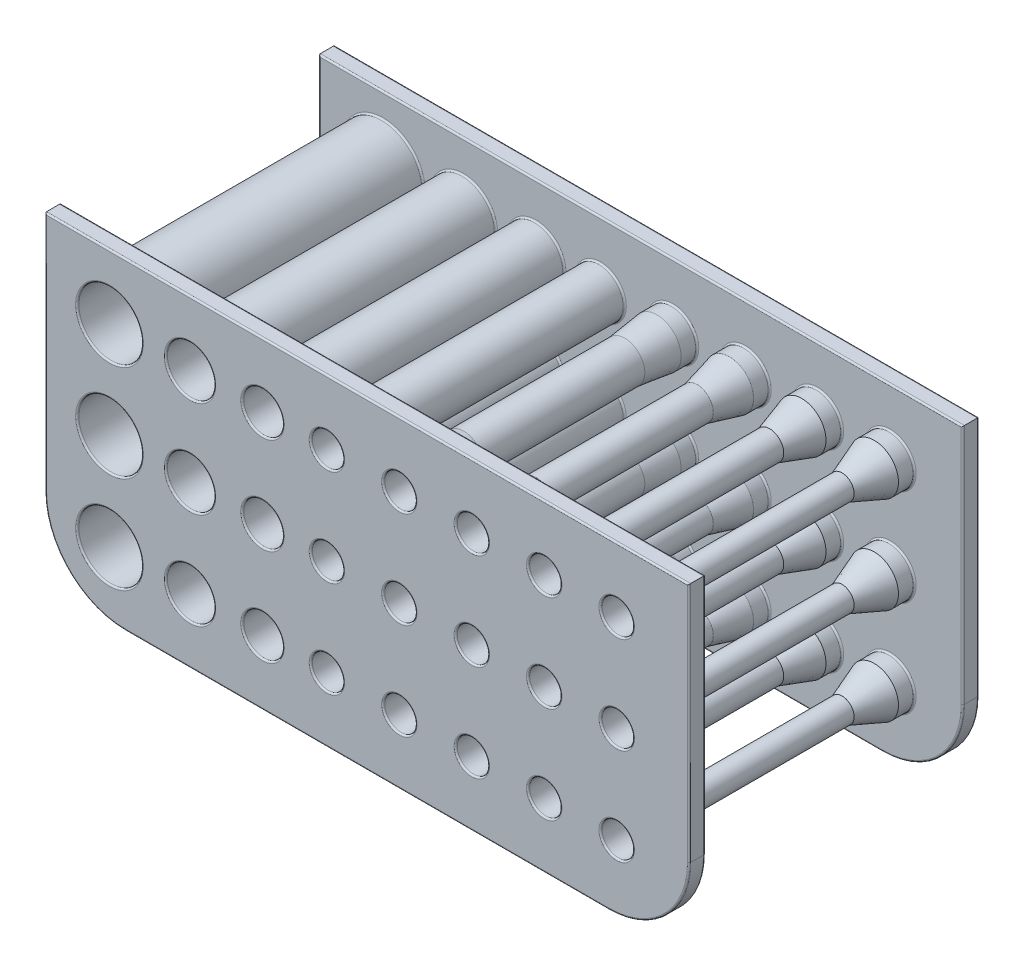
from build123d import *

# Parameters (mm, degrees)
SKIZZE1_R                   = 5
SKIZZE1_R_2                 = 4
EXTRUDE_THIN2_DEPTH         = 18
SKIZZE1_R_3                 = 3
EXTRUDE_THIN2_2_DEPTH       = 18
SKIZZE1_R_4                 = 3.5
SKIZZE1_R_5                 = 2.5
EXTRUDE_THIN2_3_DEPTH       = 18
SKIZZE1_R_6                 = 2
EXTRUDE_THIN2_4_DEPTH       = 18
SKIZZE1_R_7                 = 1.5
EXTRUDE_THIN2_5_DEPTH       = 18
SKIZZE1_R_8                 = 1
EXTRUDE_THIN2_6_DEPTH       = 18
SKIZZE1_R_9                 = 1.75
SKIZZE1_R_10                = 0.75
EXTRUDE_THIN2_7_DEPTH       = 18
SKIZZE1_R_11                = 0.5
EXTRUDE_THIN2_8_DEPTH       = 18
SKETCH1_W                   = 80
SKETCH1_H                   = 40
BOSS_EXTRUDE1_DEPTH         = 2
FILLET1_R                   = 10
LPATTERN2_COUNT             = 2
LPATTERN2_PITCH             = 34
FILLET1_OF_LPATTERN2_R      = 10
SKIZZE1_3_R                 = 4
SKIZZE1_3_R_2               = 3
SKIZZE1_3_R_3               = 2.5
SKIZZE1_3_R_4               = 2
SKIZZE1_3_R_5               = 1.5
SKIZZE1_3_R_6               = 1
SKIZZE1_3_R_7               = 0.75
SKIZZE1_3_R_8               = 0.5
CUT_EXTRUDE1_DEPTH          = 18
SKETCH7_R                   = 3
CUT_EXTRUDE2_DEPTH          = 8
SKETCH7_3_R                 = 3
SKETCH7_3_R_2               = 2
EXTRUDE_THIN3_DEPTH         = 4
LPATTERN5_COUNT             = 2
LPATTERN5_PITCH             = 12
LPATTERN5_COUNT_DIR2        = 2
LPATTERN5_PITCH_DIR2        = 12
LPATTERN5_COPY_1_SKETCH_R   = 3
LPATTERN5_COPY_1_DEPTH      = 8
LPATTERN5_COPY_2_SKETCH_R   = 3
LPATTERN5_COPY_2_DEPTH      = 8
LPATTERN5_COPY_3_SKETCH_R   = 3
LPATTERN5_COPY_3_DEPTH      = 8
LPATTERN5_COPY_4_SKETCH_R   = 3
LPATTERN5_COPY_4_SKETCH_R_2 = 2
LPATTERN5_COPY_4_DEPTH      = 4
LPATTERN5_COPY_5_SKETCH_R   = 3
LPATTERN5_COPY_5_SKETCH_R_2 = 2
LPATTERN5_COPY_5_DEPTH      = 4
LPATTERN5_COPY_6_SKETCH_R   = 3
LPATTERN5_COPY_6_SKETCH_R_2 = 2
LPATTERN5_COPY_6_DEPTH      = 4
FILLET3_R                   = 0.2


with BuildPart() as part:
    # Skizze1 → Extrude-Thin2 (new, symmetric)
    with BuildSketch(Plane.XY):
        with Locations((-32, 0)):
            Circle(SKIZZE1_R)
        with Locations((-32, 0)):
            Circle(SKIZZE1_R_2, mode=Mode.SUBTRACT)
    extrude_thin2 = extrude(amount=EXTRUDE_THIN2_DEPTH, both=True)



with BuildPart() as body_2:
    # Skizze1 → Extrude-Thin2 2 (new, symmetric)
    with BuildSketch(Plane.XY):
        with Locations((-22, 0)):
            Circle(SKIZZE1_R_2)
        with Locations((-22, 0)):
            Circle(SKIZZE1_R_3, mode=Mode.SUBTRACT)
    extrude_thin2_2 = extrude(amount=EXTRUDE_THIN2_2_DEPTH, both=True)


with BuildPart() as body_3:
    # Skizze1 → Extrude-Thin2 3 (new, symmetric)
    with BuildSketch(Plane.XY):
        with Locations((-13, 0)):
            Circle(SKIZZE1_R_4)
        with Locations((-13, 0)):
            Circle(SKIZZE1_R_5, mode=Mode.SUBTRACT)
    extrude_thin2_3 = extrude(amount=EXTRUDE_THIN2_3_DEPTH, both=True)


with BuildPart() as body_4:
    # Skizze1 → Extrude-Thin2 4 (new, symmetric)
    with BuildSketch(Plane.XY):
        with Locations((-5, 0)):
            Circle(SKIZZE1_R_3)
        with Locations((-5, 0)):
            Circle(SKIZZE1_R_6, mode=Mode.SUBTRACT)
    extrude_thin2_4 = extrude(amount=EXTRUDE_THIN2_4_DEPTH, both=True)


with BuildPart() as body_5:
    # Skizze1 → Extrude-Thin2 5 (new, symmetric)
    with BuildSketch(Plane.XY):
        with Locations((4, 0)):
            Circle(SKIZZE1_R_5)
        with Locations((4, 0)):
            Circle(SKIZZE1_R_7, mode=Mode.SUBTRACT)
    extrude_thin2_5 = extrude(amount=EXTRUDE_THIN2_5_DEPTH, both=True)


with BuildPart() as body_6:
    # Skizze1 → Extrude-Thin2 6 (new, symmetric)
    with BuildSketch(Plane.XY):
        with Locations((13, 0)):
            Circle(SKIZZE1_R_6)
        with Locations((13, 0)):
            Circle(SKIZZE1_R_8, mode=Mode.SUBTRACT)
    extrude_thin2_6 = extrude(amount=EXTRUDE_THIN2_6_DEPTH, both=True)


with BuildPart() as body_7:
    # Skizze1 → Extrude-Thin2 7 (new, symmetric)
    with BuildSketch(Plane.XY):
        with Locations((22, 0)):
            Circle(SKIZZE1_R_9)
        with Locations((22, 0)):
            Circle(SKIZZE1_R_10, mode=Mode.SUBTRACT)
    extrude_thin2_7 = extrude(amount=EXTRUDE_THIN2_7_DEPTH, both=True)


with BuildPart() as body_8:
    # Skizze1 → Extrude-Thin2 8 (new, symmetric)
    with BuildSketch(Plane.XY):
        with Locations((31, 0)):
            Circle(SKIZZE1_R_7)
        with Locations((31, 0)):
            Circle(SKIZZE1_R_11, mode=Mode.SUBTRACT)
    extrude_thin2_8 = extrude(amount=EXTRUDE_THIN2_8_DEPTH, both=True)


with BuildPart() as part_1:
    add(part.part)

    add(body_2.part)  # Boss-Extrude1 merges body 2

    add(body_3.part)  # Boss-Extrude1 merges body 3

    add(body_4.part)  # Boss-Extrude1 merges body 4

    add(body_5.part)  # Boss-Extrude1 merges body 5

    add(body_6.part)  # Boss-Extrude1 merges body 6

    add(body_7.part)  # Boss-Extrude1 merges body 7

    add(body_8.part)  # Boss-Extrude1 merges body 8
    # Sketch1 → Boss-Extrude1 (add)
    with BuildSketch(Plane.XY.offset(18)):
        Rectangle(SKETCH1_W, SKETCH1_H)
    boss_extrude1 = extrude(amount=-BOSS_EXTRUDE1_DEPTH)

    # Fillet1
    fillet1_edges = [part_1.edges().sort_by_distance(p)[0] for p in [
        (40, -20, 17),
        (-40, -20, 17),
    ]]
    fillet(fillet1_edges, radius=FILLET1_R)

    # LPattern2: Boss-Extrude1 ×2
    with Locations(*[(0, 0, -i * LPATTERN2_PITCH) for i in range(1, LPATTERN2_COUNT)]):
        add(boss_extrude1)

    # Fillet1 of LPattern2
    fillet1_of_lpattern2_edges = [part_1.edges().sort_by_distance(p)[0] for p in [
        (40, -20, -17),
        (-40, -20, -17),
    ]]
    fillet(fillet1_of_lpattern2_edges, radius=FILLET1_OF_LPATTERN2_R)

    # Skizze1_3 → Cut-Extrude1 (cut, symmetric)
    with BuildSketch(Plane.XY):
        with Locations((-32, 0)):
            Circle(SKIZZE1_3_R)
        with Locations((-22, 0)):
            Circle(SKIZZE1_3_R_2)
        with Locations((-13, 0)):
            Circle(SKIZZE1_3_R_3)
        with Locations((-5, 0)):
            Circle(SKIZZE1_3_R_4)
        with Locations((4, 0)):
            Circle(SKIZZE1_3_R_5)
        with Locations((13, 0)):
            Circle(SKIZZE1_3_R_6)
        with Locations((22, 0)):
            Circle(SKIZZE1_3_R_7)
        with Locations((31, 0)):
            Circle(SKIZZE1_3_R_8)
    cut_extrude1 = extrude(amount=CUT_EXTRUDE1_DEPTH, both=True, mode=Mode.SUBTRACT)

    # Sketch7 → Cut-Extrude2 (cut)
    with BuildSketch(Plane.XY.offset(18)):
        with Locations((31, 0)):
            Circle(SKETCH7_R)
        with Locations((22, 0)):
            Circle(SKETCH7_R)
        with Locations((13, 0)):
            Circle(SKETCH7_R)
        with Locations((4, 0)):
            Circle(SKETCH7_R)
    cut_extrude2 = extrude(amount=-CUT_EXTRUDE2_DEPTH, mode=Mode.SUBTRACT)

    # Sketch7_3 → Extrude-Thin3 (add)
    # profile 1 of 4: a face of its own
    with BuildSketch(Plane.XY.offset(18)):
        with Locations((31, 0)):
            Circle(SKETCH7_3_R)
        with Locations((31, 0)):
            Circle(SKETCH7_3_R_2, mode=Mode.SUBTRACT)
    # profile 2 of 4: a face of its own
    with BuildSketch(Plane.XY.offset(18)):
        with Locations((22, 0)):
            Circle(SKETCH7_3_R)
        with Locations((22, 0)):
            Circle(SKETCH7_3_R_2, mode=Mode.SUBTRACT)
    # profile 3 of 4: a face of its own
    with BuildSketch(Plane.XY.offset(18)):
        with Locations((13, 0)):
            Circle(SKETCH7_3_R)
        with Locations((13, 0)):
            Circle(SKETCH7_3_R_2, mode=Mode.SUBTRACT)
    # profile 4 of 4: a face of its own
    with BuildSketch(Plane.XY.offset(18)):
        with Locations((4, 0)):
            Circle(SKETCH7_3_R)
        with Locations((4, 0)):
            Circle(SKETCH7_3_R_2, mode=Mode.SUBTRACT)
    extrude_thin3 = extrude(amount=-EXTRUDE_THIN3_DEPTH)

    # Sketch8 → Revolve2 (revolve)
    with BuildSketch(Plane(origin=(0, 0, 0), x_dir=(1, 0, 0), z_dir=(0, 1, 0))):
        Polygon((6, -14), (7, -14), (6.5, -10), (5.5, -10), align=None)
    revolve2 = revolve(axis=Axis((4, 0, 14), (0, 0, 1)))

    # Sketch22 → Revolve3 (revolve)
    with BuildSketch(Plane(origin=(0, 0, 0), x_dir=(1, 0, 0), z_dir=(0, 1, 0))):
        Polygon((15, -10), (16, -14), (15, -14), (14, -10), align=None)
    revolve3 = revolve(axis=Axis((13, 0, 14), (0, 0, 1)))

    # Sketch23 → Revolve4 (revolve)
    with BuildSketch(Plane(origin=(0, 0, 0), x_dir=(1, 0, 0), z_dir=(0, 1, 0))):
        Polygon((23.75, -10), (25, -14), (24, -14), (22.75, -10), align=None)
    revolve4 = revolve(axis=Axis((22, 0, 14), (0, 0, 1)))

    # Sketch24 → Revolve5 (revolve)
    with BuildSketch(Plane(origin=(0, 0, 0), x_dir=(1, 0, 0), z_dir=(0, 1, 0))):
        Polygon((34, -14), (33, -14), (31.5, -10), (32.5, -10), align=None)
    revolve5 = revolve(axis=Axis((31, 0, 14), (0, 0, 1)))

    # Mirror6: Cut-Extrude2, Extrude-Thin3, Revolve2, Revolve3, Revolve4, Revolve5 across plane
    add(cut_extrude2.mirror(Plane.XY), mode=Mode.SUBTRACT)
    add(extrude_thin3.mirror(Plane.XY))
    add(revolve2.mirror(Plane.XY))
    add(revolve3.mirror(Plane.XY))
    add(revolve4.mirror(Plane.XY))
    add(revolve5.mirror(Plane.XY))

    # LPattern5: Extrude-Thin2, Extrude-Thin2 2, Extrude-Thin2 3, Extrude-Thin2 4, Extrude-Thin2 5, Extrude-Thin2 6, Extrude-Thin2 7, Extrude-Thin2 8, Cut-Extrude1, Cut-Extrude2, Extrude-Thin3, Revolve2, Revolve3, Revolve4, Revolve5 2 × 2
    with Locations(*[Vector(0, -1, 0) * (i * LPATTERN5_PITCH) + Vector(0, 1, 0) * (j * LPATTERN5_PITCH_DIR2) for i in range(LPATTERN5_COUNT) for j in range(LPATTERN5_COUNT_DIR2) if (i, j) != (0, 0)]):
        add(extrude_thin2)
        add(extrude_thin2_2)
        add(extrude_thin2_3)
        add(extrude_thin2_4)
        add(extrude_thin2_5)
        add(extrude_thin2_6)
        add(extrude_thin2_7)
        add(extrude_thin2_8)
        add(cut_extrude1, mode=Mode.SUBTRACT)
        add(cut_extrude2, mode=Mode.SUBTRACT)
        add(extrude_thin3)
        add(revolve2)
        add(revolve3)
        add(revolve4)
        add(revolve5)

    # LPattern5 copy 1 sketch → LPattern5 copy 1 (cut)
    with BuildSketch(Plane(origin=(0, 12, -18), x_dir=(1, 0, 0), z_dir=(0, 0, -1))):
        with Locations((31, 0)):
            Circle(LPATTERN5_COPY_1_SKETCH_R)
        with Locations((22, 0)):
            Circle(LPATTERN5_COPY_1_SKETCH_R)
        with Locations((13, 0)):
            Circle(LPATTERN5_COPY_1_SKETCH_R)
        with Locations((4, 0)):
            Circle(LPATTERN5_COPY_1_SKETCH_R)
    extrude(amount=-LPATTERN5_COPY_1_DEPTH, mode=Mode.SUBTRACT)

    # LPattern5 copy 2 sketch → LPattern5 copy 2 (cut)
    with BuildSketch(Plane(origin=(0, -12, -18), x_dir=(1, 0, 0), z_dir=(0, 0, -1))):
        with Locations((31, 0)):
            Circle(LPATTERN5_COPY_2_SKETCH_R)
        with Locations((22, 0)):
            Circle(LPATTERN5_COPY_2_SKETCH_R)
        with Locations((13, 0)):
            Circle(LPATTERN5_COPY_2_SKETCH_R)
        with Locations((4, 0)):
            Circle(LPATTERN5_COPY_2_SKETCH_R)
    extrude(amount=-LPATTERN5_COPY_2_DEPTH, mode=Mode.SUBTRACT)

    # LPattern5 copy 3 sketch → LPattern5 copy 3 (cut)
    with BuildSketch(Plane(origin=(0, 0, -18), x_dir=(1, 0, 0), z_dir=(0, 0, -1))):
        with Locations((31, 0)):
            Circle(LPATTERN5_COPY_3_SKETCH_R)
        with Locations((22, 0)):
            Circle(LPATTERN5_COPY_3_SKETCH_R)
        with Locations((13, 0)):
            Circle(LPATTERN5_COPY_3_SKETCH_R)
        with Locations((4, 0)):
            Circle(LPATTERN5_COPY_3_SKETCH_R)
    extrude(amount=-LPATTERN5_COPY_3_DEPTH, mode=Mode.SUBTRACT)

    # LPattern5 copy 4 sketch → LPattern5 copy 4 (add)
    # profile 1 of 4: a face of its own
    with BuildSketch(Plane(origin=(0, 12, -18), x_dir=(1, 0, 0), z_dir=(0, 0, -1))):
        with Locations((31, 0)):
            Circle(LPATTERN5_COPY_4_SKETCH_R)
        with Locations((31, 0)):
            Circle(LPATTERN5_COPY_4_SKETCH_R_2, mode=Mode.SUBTRACT)
    # profile 2 of 4: a face of its own
    with BuildSketch(Plane(origin=(0, 12, -18), x_dir=(1, 0, 0), z_dir=(0, 0, -1))):
        with Locations((22, 0)):
            Circle(LPATTERN5_COPY_4_SKETCH_R)
        with Locations((22, 0)):
            Circle(LPATTERN5_COPY_4_SKETCH_R_2, mode=Mode.SUBTRACT)
    # profile 3 of 4: a face of its own
    with BuildSketch(Plane(origin=(0, 12, -18), x_dir=(1, 0, 0), z_dir=(0, 0, -1))):
        with Locations((13, 0)):
            Circle(LPATTERN5_COPY_4_SKETCH_R)
        with Locations((13, 0)):
            Circle(LPATTERN5_COPY_4_SKETCH_R_2, mode=Mode.SUBTRACT)
    # profile 4 of 4: a face of its own
    with BuildSketch(Plane(origin=(0, 12, -18), x_dir=(1, 0, 0), z_dir=(0, 0, -1))):
        with Locations((4, 0)):
            Circle(LPATTERN5_COPY_4_SKETCH_R)
        with Locations((4, 0)):
            Circle(LPATTERN5_COPY_4_SKETCH_R_2, mode=Mode.SUBTRACT)
    extrude(amount=-LPATTERN5_COPY_4_DEPTH)

    # LPattern5 copy 5 sketch → LPattern5 copy 5 (add)
    # profile 1 of 4: a face of its own
    with BuildSketch(Plane(origin=(0, -12, -18), x_dir=(1, 0, 0), z_dir=(0, 0, -1))):
        with Locations((31, 0)):
            Circle(LPATTERN5_COPY_5_SKETCH_R)
        with Locations((31, 0)):
            Circle(LPATTERN5_COPY_5_SKETCH_R_2, mode=Mode.SUBTRACT)
    # profile 2 of 4: a face of its own
    with BuildSketch(Plane(origin=(0, -12, -18), x_dir=(1, 0, 0), z_dir=(0, 0, -1))):
        with Locations((22, 0)):
            Circle(LPATTERN5_COPY_5_SKETCH_R)
        with Locations((22, 0)):
            Circle(LPATTERN5_COPY_5_SKETCH_R_2, mode=Mode.SUBTRACT)
    # profile 3 of 4: a face of its own
    with BuildSketch(Plane(origin=(0, -12, -18), x_dir=(1, 0, 0), z_dir=(0, 0, -1))):
        with Locations((13, 0)):
            Circle(LPATTERN5_COPY_5_SKETCH_R)
        with Locations((13, 0)):
            Circle(LPATTERN5_COPY_5_SKETCH_R_2, mode=Mode.SUBTRACT)
    # profile 4 of 4: a face of its own
    with BuildSketch(Plane(origin=(0, -12, -18), x_dir=(1, 0, 0), z_dir=(0, 0, -1))):
        with Locations((4, 0)):
            Circle(LPATTERN5_COPY_5_SKETCH_R)
        with Locations((4, 0)):
            Circle(LPATTERN5_COPY_5_SKETCH_R_2, mode=Mode.SUBTRACT)
    extrude(amount=-LPATTERN5_COPY_5_DEPTH)

    # LPattern5 copy 6 sketch → LPattern5 copy 6 (add)
    # profile 1 of 4: a face of its own
    with BuildSketch(Plane(origin=(0, 0, -18), x_dir=(1, 0, 0), z_dir=(0, 0, -1))):
        with Locations((31, 0)):
            Circle(LPATTERN5_COPY_6_SKETCH_R)
        with Locations((31, 0)):
            Circle(LPATTERN5_COPY_6_SKETCH_R_2, mode=Mode.SUBTRACT)
    # profile 2 of 4: a face of its own
    with BuildSketch(Plane(origin=(0, 0, -18), x_dir=(1, 0, 0), z_dir=(0, 0, -1))):
        with Locations((22, 0)):
            Circle(LPATTERN5_COPY_6_SKETCH_R)
        with Locations((22, 0)):
            Circle(LPATTERN5_COPY_6_SKETCH_R_2, mode=Mode.SUBTRACT)
    # profile 3 of 4: a face of its own
    with BuildSketch(Plane(origin=(0, 0, -18), x_dir=(1, 0, 0), z_dir=(0, 0, -1))):
        with Locations((13, 0)):
            Circle(LPATTERN5_COPY_6_SKETCH_R)
        with Locations((13, 0)):
            Circle(LPATTERN5_COPY_6_SKETCH_R_2, mode=Mode.SUBTRACT)
    # profile 4 of 4: a face of its own
    with BuildSketch(Plane(origin=(0, 0, -18), x_dir=(1, 0, 0), z_dir=(0, 0, -1))):
        with Locations((4, 0)):
            Circle(LPATTERN5_COPY_6_SKETCH_R)
        with Locations((4, 0)):
            Circle(LPATTERN5_COPY_6_SKETCH_R_2, mode=Mode.SUBTRACT)
    extrude(amount=-LPATTERN5_COPY_6_DEPTH)

    # LPattern5 copy 7 sketch → LPattern5 copy 7 (revolve)
    with BuildSketch(Plane(origin=(0, 12, 0), x_dir=(1, 0, 0), z_dir=(0, 1, 0))):
        Polygon((6, 14), (7, 14), (6.5, 10), (5.5, 10), align=None)
    revolve(axis=Axis((4, 12, -14), (0, 0, 1)))

    # LPattern5 copy 8 sketch → LPattern5 copy 8 (revolve)
    with BuildSketch(Plane(origin=(0, -12, 0), x_dir=(1, 0, 0), z_dir=(0, 1, 0))):
        Polygon((6, 14), (7, 14), (6.5, 10), (5.5, 10), align=None)
    revolve(axis=Axis((4, -12, -14), (0, 0, 1)))

    # LPattern5 copy 9 sketch → LPattern5 copy 9 (revolve)
    with BuildSketch(Plane(origin=(0, 0, 0), x_dir=(1, 0, 0), z_dir=(0, 1, 0))):
        Polygon((6, 14), (7, 14), (6.5, 10), (5.5, 10), align=None)
    revolve(axis=Axis((4, 0, -14), (0, 0, 1)))

    # LPattern5 copy 10 sketch → LPattern5 copy 10 (revolve)
    with BuildSketch(Plane(origin=(0, 12, 0), x_dir=(1, 0, 0), z_dir=(0, 1, 0))):
        Polygon((15, 10), (16, 14), (15, 14), (14, 10), align=None)
    revolve(axis=Axis((13, 12, -14), (0, 0, 1)))

    # LPattern5 copy 11 sketch → LPattern5 copy 11 (revolve)
    with BuildSketch(Plane(origin=(0, -12, 0), x_dir=(1, 0, 0), z_dir=(0, 1, 0))):
        Polygon((15, 10), (16, 14), (15, 14), (14, 10), align=None)
    revolve(axis=Axis((13, -12, -14), (0, 0, 1)))

    # LPattern5 copy 12 sketch → LPattern5 copy 12 (revolve)
    with BuildSketch(Plane(origin=(0, 0, 0), x_dir=(1, 0, 0), z_dir=(0, 1, 0))):
        Polygon((15, 10), (16, 14), (15, 14), (14, 10), align=None)
    revolve(axis=Axis((13, 0, -14), (0, 0, 1)))

    # LPattern5 copy 13 sketch → LPattern5 copy 13 (revolve)
    with BuildSketch(Plane(origin=(0, 12, 0), x_dir=(1, 0, 0), z_dir=(0, 1, 0))):
        Polygon((23.75, 10), (25, 14), (24, 14), (22.75, 10), align=None)
    revolve(axis=Axis((22, 12, -14), (0, 0, 1)))

    # LPattern5 copy 14 sketch → LPattern5 copy 14 (revolve)
    with BuildSketch(Plane(origin=(0, -12, 0), x_dir=(1, 0, 0), z_dir=(0, 1, 0))):
        Polygon((23.75, 10), (25, 14), (24, 14), (22.75, 10), align=None)
    revolve(axis=Axis((22, -12, -14), (0, 0, 1)))

    # LPattern5 copy 15 sketch → LPattern5 copy 15 (revolve)
    with BuildSketch(Plane(origin=(0, 0, 0), x_dir=(1, 0, 0), z_dir=(0, 1, 0))):
        Polygon((23.75, 10), (25, 14), (24, 14), (22.75, 10), align=None)
    revolve(axis=Axis((22, 0, -14), (0, 0, 1)))

    # LPattern5 copy 16 sketch → LPattern5 copy 16 (revolve)
    with BuildSketch(Plane(origin=(0, 12, 0), x_dir=(1, 0, 0), z_dir=(0, 1, 0))):
        Polygon((34, 14), (33, 14), (31.5, 10), (32.5, 10), align=None)
    revolve(axis=Axis((31, 12, -14), (0, 0, 1)))

    # LPattern5 copy 17 sketch → LPattern5 copy 17 (revolve)
    with BuildSketch(Plane(origin=(0, -12, 0), x_dir=(1, 0, 0), z_dir=(0, 1, 0))):
        Polygon((34, 14), (33, 14), (31.5, 10), (32.5, 10), align=None)
    revolve(axis=Axis((31, -12, -14), (0, 0, 1)))

    # LPattern5 copy 18 sketch → LPattern5 copy 18 (revolve)
    with BuildSketch(Plane(origin=(0, 0, 0), x_dir=(1, 0, 0), z_dir=(0, 1, 0))):
        Polygon((34, 14), (33, 14), (31.5, 10), (32.5, 10), align=None)
    revolve(axis=Axis((31, 0, -14), (0, 0, 1)))

    # Fillet3
    fillet3_edges = [part_1.edges().sort_by_distance(p)[0] for p in [
        (2, 0, -18),
        (11, 0, -18),
        (20, 0, -18),
        (29, 0, -18),
        (2, -12, -18),
        (11, -12, -18),
        (20, -12, -18),
        (29, -12, -18),
        (2, 12, -18),
        (11, 12, -18),
        (20, 12, -18),
        (29, 12, -18),
        (-15.5, 0, -18),
        (-36, 0, -18),
        (0, 20, -18),
        (-40, 5, -18),
        (-37.071067812, -17.071067812, -18),
        (0, -20, -18),
        (37.071067812, -17.071067812, -18),
        (40, 5, -18),
        (-25, 0, -18),
        (-7, 0, -18),
        (-36, 12, -18),
        (-36, -12, -18),
        (-7, 12, -18),
        (-15.5, 12, -18),
        (-25, 12, -18),
        (-7, -12, -18),
        (-15.5, -12, -18),
        (-25, -12, -18),
        (-37.071067812, -17.071067812, -16),
        (-40, 5, -16),
        (0, 20, -16),
        (40, 5, -16),
        (37.071067812, -17.071067812, -16),
        (0, -20, -16),
        (-8, 0, -16),
        (-16.5, 0, -16),
        (-26, 0, -16),
        (-37, 0, -16),
        (1, 0, -16),
        (10, 0, -16),
        (19, 0, -16),
        (28, 0, -16),
        (-37, 12, -16),
        (-26, 12, -16),
        (-16.5, 12, -16),
        (-8, 12, -16),
        (-37, -12, -16),
        (-26, -12, -16),
        (-16.5, -12, -16),
        (-8, -12, -16),
        (1, 12, -16),
        (10, 12, -16),
        (19, 12, -16),
        (28, 12, -16),
        (1, -12, -16),
        (10, -12, -16),
        (19, -12, -16),
        (28, -12, -16),
        (2, 0, 18),
        (11, 0, 18),
        (20, 0, 18),
        (29, 0, 18),
        (2, -12, 18),
        (11, -12, 18),
        (20, -12, 18),
        (29, -12, 18),
        (2, 12, 18),
        (11, 12, 18),
        (20, 12, 18),
        (29, 12, 18),
        (-15.5, 0, 18),
        (-36, 0, 18),
        (-37.071067812, -17.071067812, 18),
        (-40, 5, 18),
        (0, 20, 18),
        (40, 5, 18),
        (37.071067812, -17.071067812, 18),
        (0, -20, 18),
        (-25, 0, 18),
        (-7, 0, 18),
        (-36, 12, 18),
        (-36, -12, 18),
        (-7, 12, 18),
        (-15.5, 12, 18),
        (-25, 12, 18),
        (-7, -12, 18),
        (-15.5, -12, 18),
        (-25, -12, 18),
        (0, 20, 16),
        (-40, 5, 16),
        (-37.071067812, -17.071067812, 16),
        (0, -20, 16),
        (37.071067812, -17.071067812, 16),
        (40, 5, 16),
        (-37, 0, 16),
        (-26, 0, 16),
        (-16.5, 0, 16),
        (-8, 0, 16),
        (1, 0, 16),
        (10, 0, 16),
        (19, 0, 16),
        (28, 0, 16),
        (-37, 12, 16),
        (-26, 12, 16),
        (-16.5, 12, 16),
        (-8, 12, 16),
        (-37, -12, 16),
        (-26, -12, 16),
        (-16.5, -12, 16),
        (-8, -12, 16),
        (28, 12, 16),
        (28, -12, 16),
        (1, 12, 16),
        (10, 12, 16),
        (19, 12, 16),
        (1, -12, 16),
        (10, -12, 16),
        (19, -12, 16),
    ]]
    fillet(fillet3_edges, radius=FILLET3_R)


solid = part_1.part
